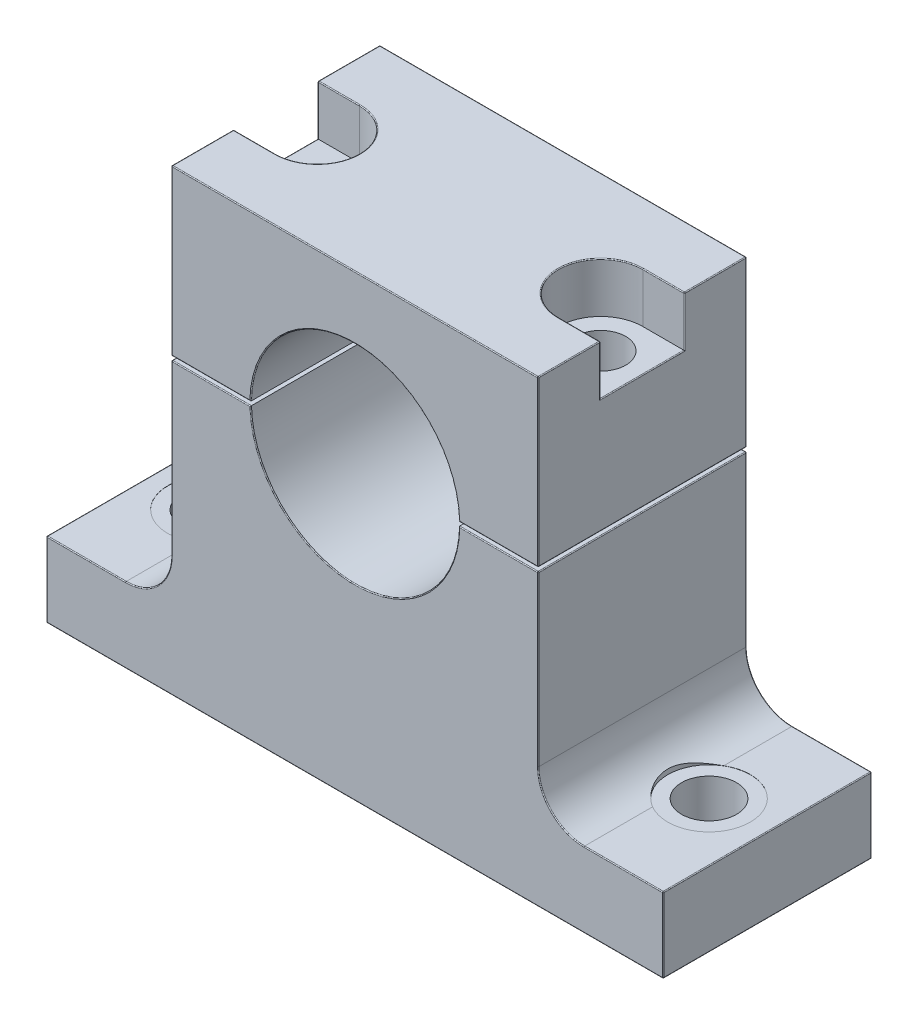
from build123d import *

# Parameters (mm, degrees)
BOSS_EXTRUDE1_DEPTH     = 12.5
BOSS_EXTRUDE1_2_DEPTH   = 12.5
SKETCH4_R               = 3.3
CUT_EXTRUDE1_DEPTH      = 61.342770901
SKETCH5_R               = 4.95
CUT_EXTRUDE2_DEPTH      = 61.342770901
CUT_EXTRUDE2_DEPTH_BACK = 0.02
SKETCH6_R               = 5.05
CUT_EXTRUDE3_DEPTH      = 6
CUT_EXTRUDE6_DEPTH      = 6
SKETCH8_R               = 3
CUT_EXTRUDE4_DEPTH      = 68.455540933
FILLET1_R               = 0.1
FILLET2_R               = 0.1


with BuildPart() as part:
    # Sketch2 → Boss-Extrude1 (new, symmetric)
    with BuildSketch(Plane.XY):
        with BuildLine():
            Line((-22, 20), (22, 20))
            Line((22, 20), (22, 0.25))
            Line((22, 0.25), (12.49749975, 0.25))
            ThreePointArc((12.49749975, 0.25), (0, 12.5), (-12.49749975, 0.25))
            Line((-12.49749975, 0.25), (-22, 0.25))
            Line((-22, 0.25), (-22, 20))
        make_face()
    extrude(amount=BOSS_EXTRUDE1_DEPTH, both=True)

    # Sketch6 → Cut-Extrude3 (cut)
    with BuildSketch(Plane(origin=(0, 20, 0), x_dir=(1, 0, 0), z_dir=(0, 1, 0))):
        with Locations((-17, 0)):
            Circle(SKETCH6_R)
        with Locations((17, 0)):
            Circle(SKETCH6_R)
    extrude(amount=-CUT_EXTRUDE3_DEPTH, mode=Mode.SUBTRACT)

    # Sketch12 → Cut-Extrude6 (cut)
    with BuildSketch(Plane(origin=(0, 20, 0), x_dir=(1, 0, 0), z_dir=(0, 1, 0))):
        with BuildLine():
            Line((-17, 5.05), (-22, 5.05))
            Line((-22, 5.05), (-22, -5.05))
            Line((-22, -5.05), (-17, -5.05))
            ThreePointArc((-17, -5.05), (-11.95, 0), (-17, 5.05))
        make_face()
        with BuildLine():
            Line((22, -5.05), (17, -5.05))
            ThreePointArc((17, -5.05), (11.95, 0), (17, 5.05))
            Line((17, 5.05), (22, 5.05))
            Line((22, 5.05), (22, -5.05))
        make_face()
    extrude(amount=-CUT_EXTRUDE6_DEPTH, mode=Mode.SUBTRACT)


with BuildPart() as body_2:
    # Sketch2 → Boss-Extrude1 2 (new, symmetric)
    with BuildSketch(Plane.XY):
        with BuildLine():
            Line((37, -35), (-37, -35))
            Line((-37, -35), (-37, -26))
            Line((-37, -26), (-27.5, -26))
            ThreePointArc((-27.5, -26), (-23.610912703, -24.389087297), (-22, -20.5))
            Line((-22, -20.5), (-22, -0.25))
            Line((-22, -0.25), (-12.49749975, -0.25))
            ThreePointArc((-12.49749975, -0.25), (0, -12.5), (12.49749975, -0.25))
            Line((12.49749975, -0.25), (22, -0.25))
            Line((22, -0.25), (22, -20.5))
            ThreePointArc((22, -20.5), (23.610912703, -24.389087297), (27.5, -26))
            Line((27.5, -26), (37, -26))
            Line((37, -26), (37, -35))
        make_face()
    extrude(amount=BOSS_EXTRUDE1_2_DEPTH, both=True)

    # Sketch4 → Cut-Extrude1 (cut, through all)
    with BuildSketch(Plane(origin=(0, -26, 0), x_dir=(1, 0, 0), z_dir=(0, 1, 0))):
        with Locations(Location((-30, 0, 0), (0, 0, 180))):
            Circle(SKETCH4_R)
        with Locations(Location((30, 0, 0), (0, 0, 180))):
            Circle(SKETCH4_R)
    extrude(amount=-CUT_EXTRUDE1_DEPTH, mode=Mode.SUBTRACT)

    # Sketch5 → Cut-Extrude2 (cut, two sides)
    with BuildSketch(Plane(origin=(0, -26, 0), x_dir=(1, 0, 0), z_dir=(0, 1, 0))) as cut_extrude2_sk:
        with Locations(Location((30, 0, 0), (0, 0, 239.665294942))):
            Circle(SKETCH5_R)
        with Locations(Location((-30, 0, 0), (0, 0, 300.334705058))):
            Circle(SKETCH5_R)
    extrude(amount=CUT_EXTRUDE2_DEPTH, mode=Mode.SUBTRACT)
    extrude(cut_extrude2_sk.sketch, amount=-CUT_EXTRUDE2_DEPTH_BACK, mode=Mode.SUBTRACT)


with BuildPart() as cut_extrude4_tool:
    # Sketch8 → Cut-Extrude4 (new, through all)
    with BuildSketch(Plane(origin=(0, 20, 0), x_dir=(1, 0, 0), z_dir=(0, 1, 0))):
        with Locations(Location((17, 0, 0), (0, 0, 180))):
            Circle(SKETCH8_R)
        with Locations(Location((-17, 0, 0), (0, 0, 180))):
            Circle(SKETCH8_R)
    extrude(amount=-CUT_EXTRUDE4_DEPTH)


with BuildPart() as part_1:
    add(part.part)

    # Cut-Extrude4: cut by cut_extrude4_tool
    add(cut_extrude4_tool.part, mode=Mode.SUBTRACT)

    # Fillet2
    fillet2_edges = [part_1.edges().sort_by_distance(p)[0] for p in [
        (0, 12.5, 12.5),
        (-22, 20, 8.775),
        (22, 20, 8.775),
        (22, 0.25, 0),
        (-22, 0.25, 0),
        (17.248749875, 0.25, 12.5),
        (22, 10.125, 12.5),
        (0, 20, 12.5),
        (22, 14, 0),
        (-22, 14, 0),
        (-11.95, 20, 0),
        (-22, 10.125, 12.5),
        (11.95, 20, 0),
        (-22, 20, -8.775),
        (22, 20, -8.775),
        (-22, 17, 5.05),
        (-19.5, 20, -5.05),
        (-19.5, 20, 5.05),
        (-22, 17, -5.05),
        (22, 17, -5.05),
        (19.5, 20, -5.05),
        (19.5, 20, 5.05),
        (0, 20, -12.5),
        (22, 17, 5.05),
        (22, 10.125, -12.5),
        (17.248749875, 0.25, -12.5),
        (-17.248749875, 0.25, 12.5),
        (0, 12.5, -12.5),
        (-17.248749875, 0.25, -12.5),
        (-22, 10.125, -12.5),
    ]]
    fillet(fillet2_edges, radius=FILLET2_R)


with BuildPart() as body_2_1:
    add(body_2.part)

    # Cut-Extrude4: cut by cut_extrude4_tool
    add(cut_extrude4_tool.part, mode=Mode.SUBTRACT)

    # Fillet1
    fillet1_edges = [body_2_1.edges().sort_by_distance(p)[0] for p in [
        (23.610912703, -24.389087297, 12.5),
        (0, -35, -12.5),
        (-37, -30.5, -12.5),
        (-32.25, -26, -12.5),
        (-23.610912703, -24.389087297, -12.5),
        (-22, -10.375, -12.5),
        (-17.248749875, -0.25, -12.5),
        (22, -10.375, 12.5),
        (0, -12.5, -12.5),
        (17.248749875, -0.25, -12.5),
        (22, -10.375, -12.5),
        (23.610912703, -24.389087297, -12.5),
        (32.25, -26, -12.5),
        (37, -30.5, -12.5),
        (17.248749875, -0.25, 12.5),
        (0, -12.5, 12.5),
        (37, -35, 0),
        (-37, -35, 0),
        (-37, -26, 0),
        (-22, -0.25, 0),
        (22, -0.25, 0),
        (37, -26, 0),
        (-17.248749875, -0.25, 12.5),
        (-22, -10.375, 12.5),
        (-23.610912703, -24.389087297, 12.5),
        (-32.25, -26, 12.5),
        (-37, -30.5, 12.5),
        (0, -35, 12.5),
        (37, -30.5, 12.5),
        (32.25, -26, 12.5),
    ]]
    fillet(fillet1_edges, radius=FILLET1_R)


solid = Compound([part_1.part, body_2_1.part])
